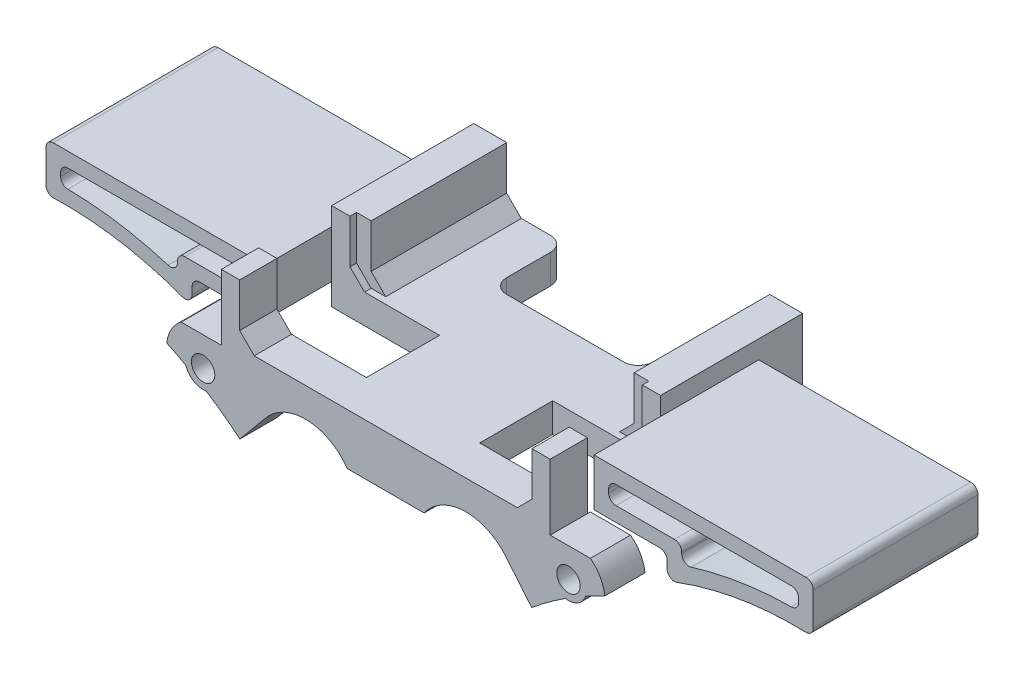
from build123d import *

# Parameters (mm, degrees)
EXTRUDE_1_DEPTH          = 34.55
SKETCH_2_W               = 40
SKETCH_2_H               = 8
CUT_EXTRUDE_1_DEPTH      = 16
CHAMFER_1_SIZE           = 2
SKETCH_6_R               = 1.6
EXTRUDE_2_DEPTH          = 6.9
SKETCH_8_R               = 1.6
EXTRUDE_3_DEPTH          = 5.5
CUT_EXTRUDE_6_DEPTH      = 10
CUT_EXTRUDE_7_DEPTH      = 25
CUT_EXTRUDE_8_DEPTH      = 25
CUT_EXTRUDE_8_DEPTH_BACK = 25
SKETCH_14_W              = 20
SKETCH_14_H              = 10
CUT_EXTRUDE_9_DEPTH      = 25
FILLET_1_R               = 2
EXTRUDE_START            = -6
EXTRUDE_4_DEPTH          = 22.55
FILLET_2_R               = 1


with BuildPart() as part:
    # 草图1 → 凸台-拉伸1 (new body)
    with BuildSketch(Plane.XY):
        Polygon((0, 0), (22.5, 0), (22.5, 12), (-22.5, 12), (-22.5, 0), align=None)
    extrude(amount=EXTRUDE_1_DEPTH)

    # 草图2 → 切除-拉伸1 (cut)
    with BuildSketch(Plane.XY.offset(34.55)):
        with Locations((0, 8)):
            Rectangle(SKETCH_2_W, SKETCH_2_H)
    extrude(amount=-CUT_EXTRUDE_1_DEPTH, mode=Mode.SUBTRACT)

    # 倒角1
    chamfer_1_edges = [part.edges().sort_by_distance(p)[0] for p in [
        (20, 4, 26.55),
        (-20, 4, 26.55),
    ]]
    chamfer(chamfer_1_edges, length=CHAMFER_1_SIZE)

    # 草图6 → 凸台-拉伸2 (add)
    with BuildSketch(Plane(origin=(0, 12, 0), x_dir=(1, 0, 0), z_dir=(0, 1, 0))):
        with BuildLine():
            Line((22.5, 0), (22.5, -13.5))
            Line((22.5, -13.5), (17, -13.5))
            ThreePointArc((17, -13.5), (15.232233047, -12.767766953), (14.5, -11))
            Line((14.5, -11), (14.5, -5))
            Line((14.5, -5), (14.5, 0))
            Line((14.5, 0), (22.5, 0))
        make_face()
        with Locations((17, -5)):
            Circle(SKETCH_6_R, mode=Mode.SUBTRACT)
        with Locations((17, -11)):
            Circle(SKETCH_6_R, mode=Mode.SUBTRACT)
        with BuildLine():
            Line((-14.5, 0), (-22.5, 0))
            Line((-22.5, 0), (-22.5, -13.5))
            Line((-22.5, -13.5), (-17, -13.5))
            ThreePointArc((-17, -13.5), (-15.232233047, -12.767766953), (-14.5, -11))
            Line((-14.5, -11), (-14.5, -5))
            Line((-14.5, -5), (-14.5, 0))
        make_face()
        with Locations((-17, -11)):
            Circle(SKETCH_6_R, mode=Mode.SUBTRACT)
        with Locations((-17, -5)):
            Circle(SKETCH_6_R, mode=Mode.SUBTRACT)
    extrude(amount=-EXTRUDE_2_DEPTH)

    # 草图8 → 凸台-拉伸3 (add)
    with BuildSketch(Plane.XY.offset(34.55)):
        with BuildLine():
            Line((1.843049286, -25.367101461), (9.230566594, -19.615105309))
            ThreePointArc((9.230566594, -19.615105309), (9.814108465, -18.625953935), (10.421644381, -17.651355727))
            Line((10.421644381, -17.651355727), (5.476763257, -11.300448334))
            ThreePointArc((5.476763257, -11.300448334), (6.699551666, -1.476763257), (16.523236743, -2.699551666))
            Line((16.523236743, -2.699551666), (19.967990067, -6.846461039))
            ThreePointArc((19.967990067, -6.846461039), (22.224318463, -5.085470923), (24.58365332, -3.465087309))
            ThreePointArc((24.58365332, -3.465087309), (26.278709649, -3.148232211), (27.365383934, -1.809295278))
            ThreePointArc((27.365383934, -1.809295278), (28.658809968, -1.124546474), (29.972928279, -0.480399834))
            ThreePointArc((29.972928279, -0.480399834), (29.349734714, 1.46572665), (28, 3))
            Line((28, 3), (22.5, 3))
            Line((22.5, 3), (22.5, 4))
            Line((22.5, 4), (-22.5, 4))
            Line((-22.5, 4), (-22.5, 3))
            Line((-22.5, 3), (-28, 3))
            ThreePointArc((-28, 3), (-29.349734714, 1.46572665), (-29.972928279, -0.480399834))
            ThreePointArc((-29.972928279, -0.480399834), (-28.658809968, -1.124546474), (-27.365383934, -1.809295278))
            ThreePointArc((-27.365383934, -1.809295278), (-26.278709649, -3.148232211), (-24.58365332, -3.465087309))
            ThreePointArc((-24.58365332, -3.465087309), (-22.224318463, -5.085470923), (-19.967990067, -6.846461039))
            Line((-19.967990067, -6.846461039), (-16.523236743, -2.699551666))
            ThreePointArc((-16.523236743, -2.699551666), (-6.699551666, -1.476763257), (-5.476763257, -11.300448334))
            Line((-5.476763257, -11.300448334), (-10.421644381, -17.651355727))
            ThreePointArc((-10.421644381, -17.651355727), (-9.814108465, -18.625953935), (-9.230566594, -19.615105309))
            Line((-9.230566594, -19.615105309), (-1.843049286, -25.367101461))
            ThreePointArc((-1.843049286, -25.367101461), (0, -26), (1.843049286, -25.367101461))
        make_face()
        with Locations((25, -1)):
            Circle(SKETCH_8_R, mode=Mode.SUBTRACT)
        with Locations((0, -23)):
            Circle(SKETCH_8_R, mode=Mode.SUBTRACT)
        with Locations((-25, -1)):
            Circle(SKETCH_8_R, mode=Mode.SUBTRACT)
    extrude(amount=-EXTRUDE_3_DEPTH)

    # 草图11 → 切除-拉伸6 (cut)
    with BuildSketch(Plane(origin=(0, 0, 29.05), x_dir=(-1, 0, 0), z_dir=(0, 0, -1))):
        Polygon((-4, -7), (-10.421644381, -17.651355727), (-10.421644381, -27.0891889), (10.421644381, -27.0891889), (10.421644381, -17.651355727), (4, -7), (5.255437353, -3), (0, -3), (-5.255437353, -3), align=None)
    extrude(amount=-CUT_EXTRUDE_6_DEPTH, mode=Mode.SUBTRACT)

    # 草图12 → 切除-拉伸7 (cut)
    with BuildSketch(Plane.XY.offset(18.55)):
        Polygon((-18, 6), (-16, 4), (16, 4), (18, 6), (18, 12), (-18, 12), align=None)
    extrude(amount=-CUT_EXTRUDE_7_DEPTH, mode=Mode.SUBTRACT)

    # 草图13 → 切除-拉伸8 (cut, two sides)
    with BuildSketch(Plane(origin=(0, 4, 0), x_dir=(1, 0, 0), z_dir=(0, 1, 0))) as cut_extrude_8_sk:
        Polygon((-7.75, -24.45), (-7.75, -28.45), (-7.75, -29.45), (-22.5, -29.45), (-22.5, -28.45), (-22.5, -24.45), (-22.5, -21.45), (-22.5, -19.45), (-7.75, -19.45), align=None)
        Polygon((22.5, -19.45), (22.5, -21.45), (22.5, -24.45), (22.5, -28.45), (22.5, -29.45), (7.75, -29.45), (7.75, -28.45), (7.75, -24.45), (7.75, -19.45), align=None)
    extrude(amount=CUT_EXTRUDE_8_DEPTH, mode=Mode.SUBTRACT)
    extrude(cut_extrude_8_sk.sketch, amount=-CUT_EXTRUDE_8_DEPTH_BACK, mode=Mode.SUBTRACT)

    # 草图14 → 切除-拉伸9 (cut)
    with BuildSketch(Plane(origin=(0, 4, 0), x_dir=(1, 0, 0), z_dir=(0, 1, 0))):
        with Locations((0, -5)):
            Rectangle(SKETCH_14_W, SKETCH_14_H)
    extrude(amount=-CUT_EXTRUDE_9_DEPTH, mode=Mode.SUBTRACT)

    # 圆角1
    fillet_1_edges = [part.edges().sort_by_distance(p)[0] for p in [
        (10, 2, 0),
        (-10, 2, 0),
        (10, 2, 10),
        (-10, 2, 10),
    ]]
    fillet(fillet_1_edges, radius=FILLET_1_R)

    # 草图15 → 凸台-拉伸4 (add)
    with BuildSketch(Plane(origin=(0, 0, 0), x_dir=(-1, 0, 0), z_dir=(0, 0, -1)).offset(EXTRUDE_START)):
        with BuildLine():
            Line((-22.5, 9.5), (-22.5, 3))
            Line((-22.5, 3), (-32.5, 3))
            Line((-32.5, 3), (-32.5, -0.458843457))
            ThreePointArc((-32.5, -0.458843457), (-42.310755549, 2.352789548), (-52.5, 2.932014979))
            Line((-52.5, 2.932014979), (-52.5, 9.5))
            Line((-52.5, 9.5), (-22.5, 9.5))
        make_face()
        with BuildLine():
            Line((-24.5, 7.5), (-24.5, 5))
            Line((-24.5, 5), (-34.5, 5))
            Line((-34.5, 5), (-34.5, 2.428515274))
            ThreePointArc((-34.5, 2.428515274), (-42.390809061, 4.393039713), (-50.5, 4.997395763))
            Line((-50.5, 4.997395763), (-50.5, 7.5))
            Line((-50.5, 7.5), (-24.5, 7.5))
        make_face(mode=Mode.SUBTRACT)
        with BuildLine():
            Line((32.5, 3), (32.5, -0.458843457))
            ThreePointArc((32.5, -0.458843457), (42.310755549, 2.352789548), (52.5, 2.932014979))
            Line((52.5, 2.932014979), (52.5, 9.5))
            Line((52.5, 9.5), (22.5, 9.5))
            Line((22.5, 9.5), (22.5, 3))
            Line((22.5, 3), (32.5, 3))
        make_face()
        with BuildLine():
            Line((24.5, 7.5), (50.5, 7.5))
            Line((50.5, 7.5), (50.5, 4.997395763))
            ThreePointArc((50.5, 4.997395763), (42.390809061, 4.393039713), (34.5, 2.428515274))
            Line((34.5, 2.428515274), (34.5, 5))
            Line((34.5, 5), (24.5, 5))
            Line((24.5, 5), (24.5, 7.5))
        make_face(mode=Mode.SUBTRACT)
    extrude(amount=-EXTRUDE_4_DEPTH)

    # 圆角2
    fillet_2_edges = [part.edges().sort_by_distance(p)[0] for p in [
        (52.5, 9.5, 17.275),
        (32.5, 3, 17.275),
        (32.5, -0.458843457, 17.275),
        (52.5, 2.932014979, 17.275),
        (24.5, 7.5, 17.275),
        (24.5, 5, 17.275),
        (34.5, 5, 17.275),
        (34.5, 2.428515274, 17.275),
        (50.5, 4.997395763, 17.275),
        (50.5, 7.5, 17.275),
        (-52.5, 9.5, 17.275),
        (-52.5, 2.932014979, 17.275),
        (-32.5, -0.458843457, 17.275),
        (-32.5, 3, 17.275),
        (-24.5, 7.5, 17.275),
        (-50.5, 7.5, 17.275),
        (-50.5, 4.997395763, 17.275),
        (-34.5, 2.428515274, 17.275),
        (-34.5, 5, 17.275),
        (-24.5, 5, 17.275),
    ]]
    fillet(fillet_2_edges, radius=FILLET_2_R)


solid = part.part
